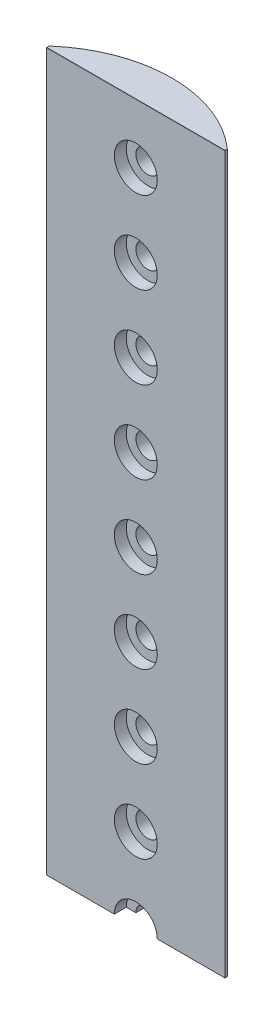
from build123d import *

# Parameters (mm, degrees)
SKETCH1_W           = 29.845
SKETCH1_H           = 120
BOSS_EXTRUDE1_DEPTH = 0.4
BOSS_EXTRUDE2_DEPTH = 120
SKETCH2_R           = 1.984375
CUT_EXTRUDE1_DEPTH  = 7.055211633
LPATTERN1_COUNT     = 15
LPATTERN1_PITCH     = 13.75
SKETCH4_R           = 3.5941
CUT_EXTRUDE2_DEPTH  = 2
LPATTERN2_COUNT     = 10
LPATTERN2_PITCH     = 13.75


with BuildPart() as part:
    # Sketch1 → Boss-Extrude1 (new body)
    with BuildSketch(Plane.XY):
        with Locations((14.9225, 60)):
            Rectangle(SKETCH1_W, SKETCH1_H)
    extrude(amount=BOSS_EXTRUDE1_DEPTH)

    # Sketch3 → Boss-Extrude2 (add, through all)
    with BuildSketch(Plane(origin=(0, 120, 0), x_dir=(1, 0, 0), z_dir=(0, 1, 0))):
        with BuildLine():
            Line((29.845, 0), (0, 0))
            ThreePointArc((0, 0), (14.9225, 5.655211633), (29.845, 0))
        make_face()
    extrude(amount=-BOSS_EXTRUDE2_DEPTH)

    # Sketch2 → Cut-Extrude1 (cut, through all)
    with BuildSketch(Plane.XY.offset(0.4)):
        with Locations((14.9225, 0)):
            Circle(SKETCH2_R)
    cut_extrude1 = extrude(amount=-CUT_EXTRUDE1_DEPTH, mode=Mode.SUBTRACT)

    # LPattern1: Cut-Extrude1 ×15
    with Locations(*[(0, i * LPATTERN1_PITCH, 0) for i in range(1, LPATTERN1_COUNT)]):
        add(cut_extrude1, mode=Mode.SUBTRACT)

    # Sketch4 → Cut-Extrude2 (cut)
    with BuildSketch(Plane.XY.offset(0.4)):
        with Locations((14.9225, 0)):
            Circle(SKETCH4_R)
    cut_extrude2 = extrude(amount=-CUT_EXTRUDE2_DEPTH, mode=Mode.SUBTRACT)

    # LPattern2: Cut-Extrude2 ×10
    with Locations(*[(0, i * LPATTERN2_PITCH, 0) for i in range(1, LPATTERN2_COUNT)]):
        add(cut_extrude2, mode=Mode.SUBTRACT)


solid = part.part
